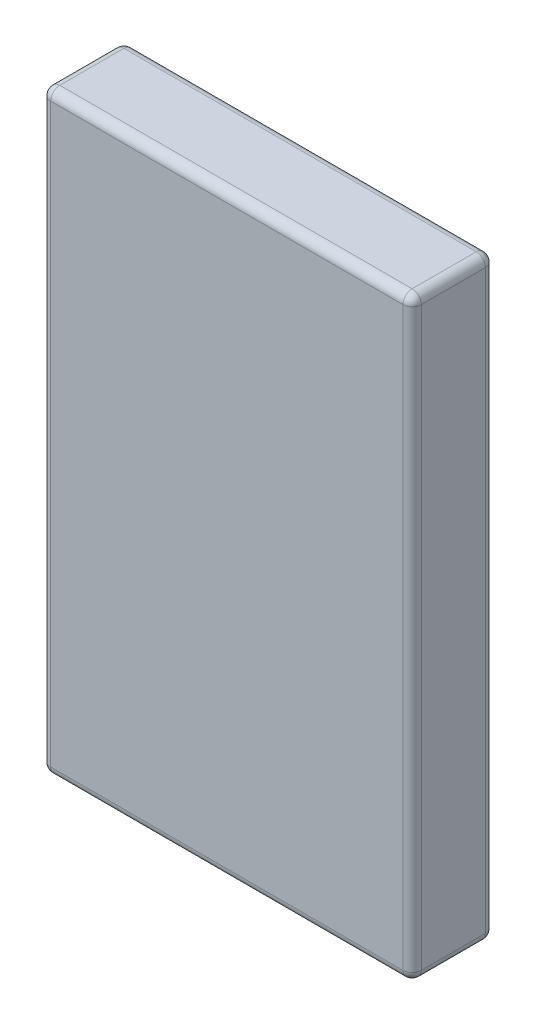
from build123d import *

# Parameters (mm, degrees)
SKETCH2_W           = 162
SKETCH2_H           = 36
BOSS_EXTRUDE1_DEPTH = 260
FILLET1_R           = 4


with BuildPart() as part:
    # Sketch2 → Boss-Extrude1 (new body)
    with BuildSketch(Plane(origin=(0, 0, 0), x_dir=(1, 0, 0), z_dir=(0, 1, 0))):
        Rectangle(SKETCH2_W, SKETCH2_H)
    extrude(amount=BOSS_EXTRUDE1_DEPTH)

    # Fillet1
    fillet1_edges = [part.edges().sort_by_distance(p)[0] for p in [
        (-81, 260, 0),
        (0, 260, 18),
        (81, 260, 0),
        (0, 0, 18),
        (-81, 0, 0),
        (0, 0, -18),
        (81, 0, 0),
        (81, 130, 18),
        (-81, 130, 18),
        (-81, 130, -18),
        (81, 130, -18),
        (0, 260, -18),
    ]]
    fillet(fillet1_edges, radius=FILLET1_R)


solid = part.part
